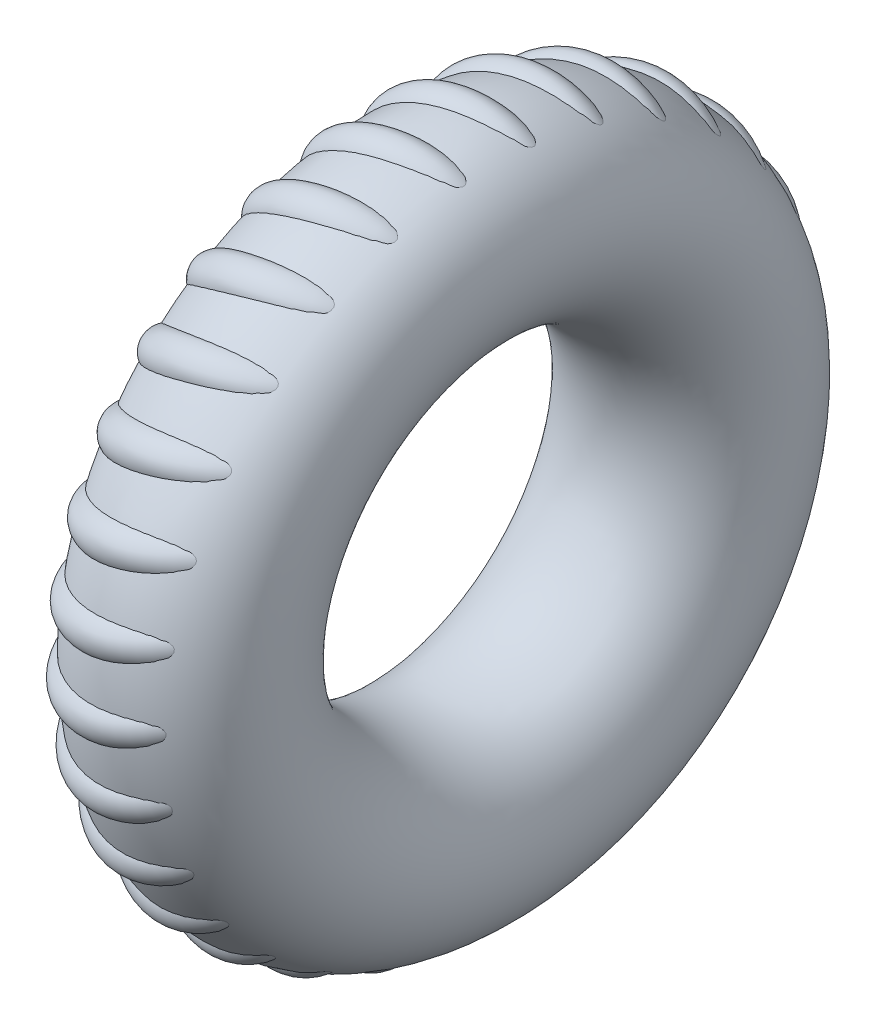
from build123d import *

# Parameters (mm, degrees)
SKETCH1_RX            = 0.3217853
SKETCH1_RY            = 0.306558502
SKETCH5_R             = 0.067304579
BODY_MOVE_COPY1_ANGLE = 10
CIRPATTERN3_COUNT     = 30


with BuildPart() as part:
    # Sketch1 → Revolve1 (revolve)
    with BuildSketch(Plane(origin=(0, 0, 0), x_dir=(-1, 0, 0), z_dir=(0, 0, -1))):
        with Locations(Location((0, 0.818475866), (0, 0, 149.825827924))):
            Ellipse(SKETCH1_RX, SKETCH1_RY)
    revolve(axis=Axis((0.318007282, 0, 0), (-1, 0, 0)))


with BuildPart() as body_2:
    # Sketch5 → Revolve3 (revolve)
    with BuildSketch(Plane.ZY):
        with Locations((-0.080665909, 1.081790187)):
            Circle(SKETCH5_R)
    revolve(axis=Axis((0, 0.862423087, -0.207317564), (0, 0.140386853048149, -0.9900967283509412)))


with BuildPart() as body_2_1:
    # Body-Move_Copy1: moved
    add(body_2.part.rotate(Axis((0, 0, 0), (0, 1, 0)), BODY_MOVE_COPY1_ANGLE))


with BuildPart() as cirpattern3_1:
    # CirPattern3: pattern copy
    add(body_2_1.part.rotate(Axis((-0.350342408, 0, 0), (1, 0, 0)), 1 * 360 / CIRPATTERN3_COUNT))


with BuildPart() as cirpattern3_2:
    # CirPattern3: pattern copy
    add(body_2_1.part.rotate(Axis((-0.350342408, 0, 0), (1, 0, 0)), 2 * 360 / CIRPATTERN3_COUNT))


with BuildPart() as cirpattern3_3:
    # CirPattern3: pattern copy
    add(body_2_1.part.rotate(Axis((-0.350342408, 0, 0), (1, 0, 0)), 3 * 360 / CIRPATTERN3_COUNT))


with BuildPart() as cirpattern3_4:
    # CirPattern3: pattern copy
    add(body_2_1.part.rotate(Axis((-0.350342408, 0, 0), (1, 0, 0)), 4 * 360 / CIRPATTERN3_COUNT))


with BuildPart() as cirpattern3_5:
    # CirPattern3: pattern copy
    add(body_2_1.part.rotate(Axis((-0.350342408, 0, 0), (1, 0, 0)), 5 * 360 / CIRPATTERN3_COUNT))


with BuildPart() as cirpattern3_6:
    # CirPattern3: pattern copy
    add(body_2_1.part.rotate(Axis((-0.350342408, 0, 0), (1, 0, 0)), 6 * 360 / CIRPATTERN3_COUNT))


with BuildPart() as cirpattern3_7:
    # CirPattern3: pattern copy
    add(body_2_1.part.rotate(Axis((-0.350342408, 0, 0), (1, 0, 0)), 7 * 360 / CIRPATTERN3_COUNT))


with BuildPart() as cirpattern3_8:
    # CirPattern3: pattern copy
    add(body_2_1.part.rotate(Axis((-0.350342408, 0, 0), (1, 0, 0)), 8 * 360 / CIRPATTERN3_COUNT))


with BuildPart() as cirpattern3_9:
    # CirPattern3: pattern copy
    add(body_2_1.part.rotate(Axis((-0.350342408, 0, 0), (1, 0, 0)), 9 * 360 / CIRPATTERN3_COUNT))


with BuildPart() as cirpattern3_10:
    # CirPattern3: pattern copy
    add(body_2_1.part.rotate(Axis((-0.350342408, 0, 0), (1, 0, 0)), 10 * 360 / CIRPATTERN3_COUNT))


with BuildPart() as cirpattern3_11:
    # CirPattern3: pattern copy
    add(body_2_1.part.rotate(Axis((-0.350342408, 0, 0), (1, 0, 0)), 11 * 360 / CIRPATTERN3_COUNT))


with BuildPart() as cirpattern3_12:
    # CirPattern3: pattern copy
    add(body_2_1.part.rotate(Axis((-0.350342408, 0, 0), (1, 0, 0)), 12 * 360 / CIRPATTERN3_COUNT))


with BuildPart() as cirpattern3_13:
    # CirPattern3: pattern copy
    add(body_2_1.part.rotate(Axis((-0.350342408, 0, 0), (1, 0, 0)), 13 * 360 / CIRPATTERN3_COUNT))


with BuildPart() as cirpattern3_14:
    # CirPattern3: pattern copy
    add(body_2_1.part.rotate(Axis((-0.350342408, 0, 0), (1, 0, 0)), 14 * 360 / CIRPATTERN3_COUNT))


with BuildPart() as cirpattern3_15:
    # CirPattern3: pattern copy
    add(body_2_1.part.rotate(Axis((-0.350342408, 0, 0), (1, 0, 0)), 15 * 360 / CIRPATTERN3_COUNT))


with BuildPart() as cirpattern3_16:
    # CirPattern3: pattern copy
    add(body_2_1.part.rotate(Axis((-0.350342408, 0, 0), (1, 0, 0)), 16 * 360 / CIRPATTERN3_COUNT))


with BuildPart() as cirpattern3_17:
    # CirPattern3: pattern copy
    add(body_2_1.part.rotate(Axis((-0.350342408, 0, 0), (1, 0, 0)), 17 * 360 / CIRPATTERN3_COUNT))


with BuildPart() as cirpattern3_18:
    # CirPattern3: pattern copy
    add(body_2_1.part.rotate(Axis((-0.350342408, 0, 0), (1, 0, 0)), 18 * 360 / CIRPATTERN3_COUNT))


with BuildPart() as cirpattern3_19:
    # CirPattern3: pattern copy
    add(body_2_1.part.rotate(Axis((-0.350342408, 0, 0), (1, 0, 0)), 19 * 360 / CIRPATTERN3_COUNT))


with BuildPart() as cirpattern3_20:
    # CirPattern3: pattern copy
    add(body_2_1.part.rotate(Axis((-0.350342408, 0, 0), (1, 0, 0)), 20 * 360 / CIRPATTERN3_COUNT))


with BuildPart() as cirpattern3_21:
    # CirPattern3: pattern copy
    add(body_2_1.part.rotate(Axis((-0.350342408, 0, 0), (1, 0, 0)), 21 * 360 / CIRPATTERN3_COUNT))


with BuildPart() as cirpattern3_22:
    # CirPattern3: pattern copy
    add(body_2_1.part.rotate(Axis((-0.350342408, 0, 0), (1, 0, 0)), 22 * 360 / CIRPATTERN3_COUNT))


with BuildPart() as cirpattern3_23:
    # CirPattern3: pattern copy
    add(body_2_1.part.rotate(Axis((-0.350342408, 0, 0), (1, 0, 0)), 23 * 360 / CIRPATTERN3_COUNT))


with BuildPart() as cirpattern3_24:
    # CirPattern3: pattern copy
    add(body_2_1.part.rotate(Axis((-0.350342408, 0, 0), (1, 0, 0)), 24 * 360 / CIRPATTERN3_COUNT))


with BuildPart() as cirpattern3_25:
    # CirPattern3: pattern copy
    add(body_2_1.part.rotate(Axis((-0.350342408, 0, 0), (1, 0, 0)), 25 * 360 / CIRPATTERN3_COUNT))


with BuildPart() as cirpattern3_26:
    # CirPattern3: pattern copy
    add(body_2_1.part.rotate(Axis((-0.350342408, 0, 0), (1, 0, 0)), 26 * 360 / CIRPATTERN3_COUNT))


with BuildPart() as cirpattern3_27:
    # CirPattern3: pattern copy
    add(body_2_1.part.rotate(Axis((-0.350342408, 0, 0), (1, 0, 0)), 27 * 360 / CIRPATTERN3_COUNT))


with BuildPart() as cirpattern3_28:
    # CirPattern3: pattern copy
    add(body_2_1.part.rotate(Axis((-0.350342408, 0, 0), (1, 0, 0)), 28 * 360 / CIRPATTERN3_COUNT))


with BuildPart() as cirpattern3_29:
    # CirPattern3: pattern copy
    add(body_2_1.part.rotate(Axis((-0.350342408, 0, 0), (1, 0, 0)), 29 * 360 / CIRPATTERN3_COUNT))


solid = Compound([part.part, body_2_1.part, cirpattern3_1.part, cirpattern3_2.part, cirpattern3_3.part, cirpattern3_4.part, cirpattern3_5.part, cirpattern3_6.part, cirpattern3_7.part, cirpattern3_8.part, cirpattern3_9.part, cirpattern3_10.part, cirpattern3_11.part, cirpattern3_12.part, cirpattern3_13.part, cirpattern3_14.part, cirpattern3_15.part, cirpattern3_16.part, cirpattern3_17.part, cirpattern3_18.part, cirpattern3_19.part, cirpattern3_20.part, cirpattern3_21.part, cirpattern3_22.part, cirpattern3_23.part, cirpattern3_24.part, cirpattern3_25.part, cirpattern3_26.part, cirpattern3_27.part, cirpattern3_28.part, cirpattern3_29.part])
